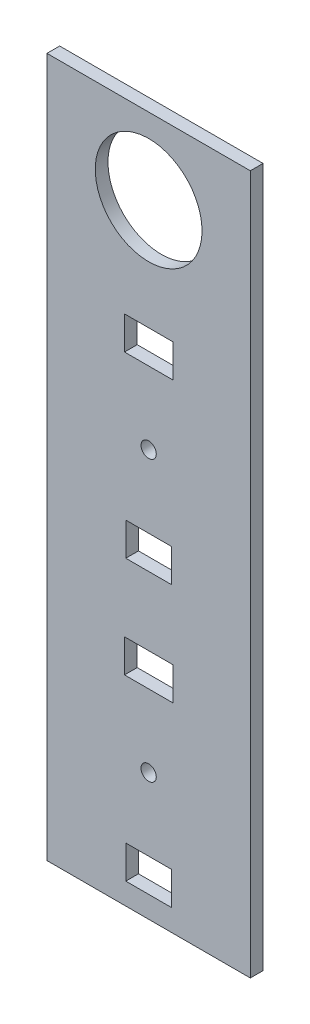
from build123d import *

# Parameters (mm, degrees)
ESQUISSE1_W             = 80
ESQUISSE1_H             = 275
BOSS_EXTRU_1_DEPTH      = 5
ESQUISSE2_R             = 21
ESQUISSE2_R_2           = 3
ESQUISSE2_W             = 18
ESQUISSE2_H             = 13
ESQUISSE2_W_2           = 19
ENL_V_MAT_EXTRU_1_DEPTH = 6


with BuildPart() as part:
    # Esquisse1 → Boss.-Extru.1 (new body)
    with BuildSketch(Plane.XY):
        Rectangle(ESQUISSE1_W, ESQUISSE1_H)
    extrude(amount=-BOSS_EXTRU_1_DEPTH)

    # Esquisse2 → Enlèv. mat.-Extru.1 (cut, through all)
    with BuildSketch(Plane.XY):
        with Locations((0, 107.5)):
            Circle(ESQUISSE2_R)
        with Locations((0, 22.5)):
            Circle(ESQUISSE2_R_2)
        with Locations((0, -87.5)):
            Circle(ESQUISSE2_R_2)
        with Locations((0, -122.5)):
            Rectangle(ESQUISSE2_W, ESQUISSE2_H)
        with Locations((0, 57.5)):
            Rectangle(ESQUISSE2_W_2, ESQUISSE2_H)
        with Locations((0, -12.5)):
            Rectangle(ESQUISSE2_W, ESQUISSE2_H)
        with Locations((0, -52.5)):
            Rectangle(ESQUISSE2_W_2, ESQUISSE2_H)
    extrude(amount=-ENL_V_MAT_EXTRU_1_DEPTH, mode=Mode.SUBTRACT)


solid = part.part
